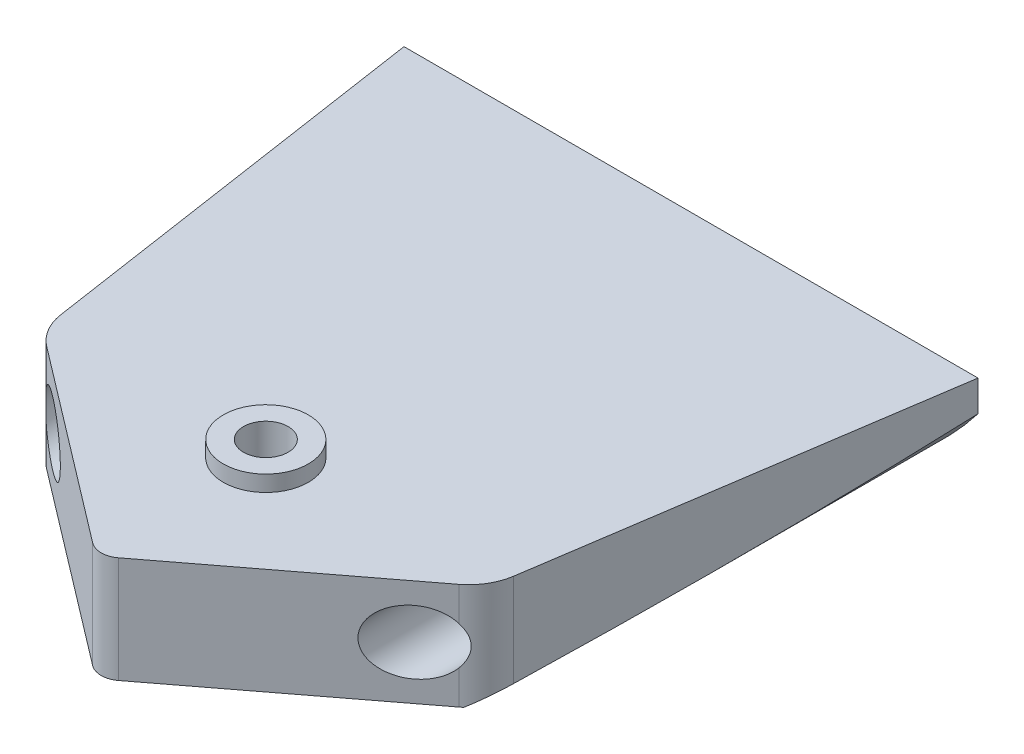
from build123d import *

# Parameters (mm, degrees)
SKETCH1_R           = 4
BOSS_EXTRUDE1_DEPTH = 10
SKETCH1_3_R         = 4
SKETCH1_3_R_2       = 2.1
BOSS_EXTRUDE2_DEPTH = 11.5
SKETCH1_4_R         = 4
SKETCH1_4_R_2       = 2.1
CUT_EXTRUDE1_DEPTH  = 3.5
SKETCH2_R           = 1.55
CUT_EXTRUDE3_DEPTH  = 61.2
SKETCH3_R           = 51.203530844
SKETCH3_R_2         = 34
CUT_EXTRUDE4_DEPTH  = 63.768674379
SKETCH4_R           = 3
CUT_EXTRUDE5_DEPTH  = 36


with BuildPart() as part:
    # Sketch1 → Boss-Extrude1 (new body)
    with BuildSketch(Plane(origin=(0, 0, 0), x_dir=(1, 0, 0), z_dir=(0, 1, 0))):
        with BuildLine():
            ThreePointArc((-21.300912355, 2.006082368), (-20.659344965, 0.201570446), (-19.386446667, -1.229373968))
            Line((-19.386446667, -1.229373968), (-1.212086431, -15.076505577))
            ThreePointArc((-1.212086431, -15.076505577), (0, -15.485642137), (1.212086431, -15.076505577))
            Line((1.212086431, -15.076505577), (19.386446667, -1.229373968))
            ThreePointArc((19.386446667, -1.229373968), (20.659344965, 0.201570446), (21.300912355, 2.006082368))
            Line((21.300912355, 2.006082368), (27, 40))
            Line((27, 40), (-27, 40))
            Line((-27, 40), (-21.300912355, 2.006082368))
        make_face()
        Circle(SKETCH1_R, mode=Mode.SUBTRACT)
    extrude(amount=BOSS_EXTRUDE1_DEPTH)

    # Sketch1_3 → Boss-Extrude2 (add)
    with BuildSketch(Plane(origin=(0, 0, 0), x_dir=(1, 0, 0), z_dir=(0, 1, 0))):
        Circle(SKETCH1_3_R)
        Circle(SKETCH1_3_R_2, mode=Mode.SUBTRACT)
    extrude(amount=BOSS_EXTRUDE2_DEPTH)

    # Sketch1_4 → Cut-Extrude1 (cut)
    with BuildSketch(Plane(origin=(0, 0, 0), x_dir=(1, 0, 0), z_dir=(0, 1, 0))):
        Circle(SKETCH1_4_R)
        Circle(SKETCH1_4_R_2, mode=Mode.SUBTRACT)
    extrude(amount=CUT_EXTRUDE1_DEPTH, mode=Mode.SUBTRACT)

    # Sketch2 → Cut-Extrude3 (cut)
    with BuildSketch(Plane(origin=(0, 0, -40), x_dir=(-1, 0, 0), z_dir=(0, 0, -1))):
        with Locations((-17, 5)):
            Circle(SKETCH2_R)
        with Locations((17, 5)):
            Circle(SKETCH2_R)
    extrude(amount=-CUT_EXTRUDE3_DEPTH, mode=Mode.SUBTRACT)

    # Sketch3 → Cut-Extrude4 (cut, through all)
    with BuildSketch(Plane(origin=(0, 0, -40), x_dir=(-1, 0, 0), z_dir=(0, 0, -1))):
        with Locations((0, 27.75)):
            Circle(SKETCH3_R)
        with Locations((0, 27.75)):
            Circle(SKETCH3_R_2, mode=Mode.SUBTRACT)
    extrude(amount=-CUT_EXTRUDE4_DEPTH, mode=Mode.SUBTRACT)

    # Sketch4 → Cut-Extrude5 (cut)
    with BuildSketch(Plane(origin=(0, 0, 20), x_dir=(-1, 0, 0), z_dir=(0, 0, -1))):
        with Locations((17, 5)):
            Circle(SKETCH4_R)
        with Locations((-17, 5)):
            Circle(SKETCH4_R)
    extrude(amount=CUT_EXTRUDE5_DEPTH, mode=Mode.SUBTRACT)


solid = part.part
